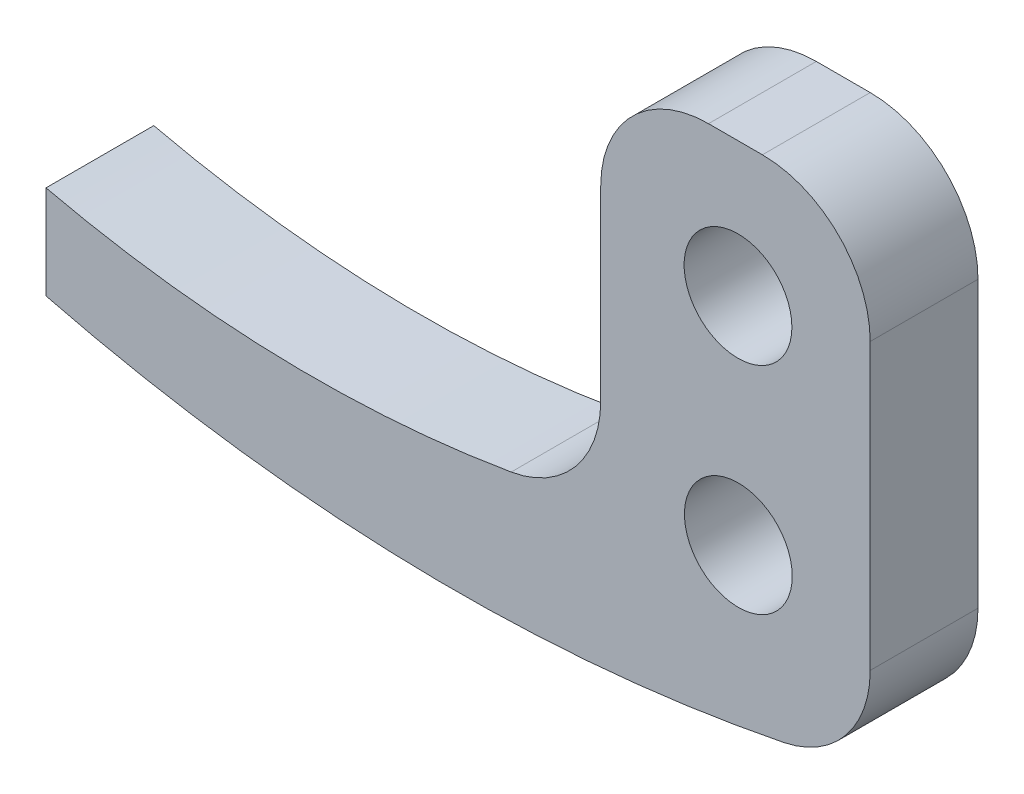
from build123d import *

# Parameters (mm, degrees)
SKETCH2_R           = 1
BOSS_EXTRUDE2_DEPTH = 2
FILLET1_R           = 2


with BuildPart() as part:
    # Sketch2 → Boss-Extrude2 (new body)
    with BuildSketch(Plane.XY):
        with BuildLine():
            Line((-3.823163379, 5.957240807), (-3.823163379, 7.694831843))
            ThreePointArc((-3.823163379, 7.694831843), (1.329416424, 7.130014771), (6.469831661, 7.796519188))
            Line((6.469831661, 7.796519188), (6.469831661, 14.872622199))
            Line((6.469831661, 14.872622199), (11.469831661, 14.872622199))
            Line((11.469831661, 14.872622199), (11.469831661, 9.743127337))
            Line((11.469831661, 9.743127337), (11.469831661, 5.993601449))
            ThreePointArc((11.469831661, 5.993601449), (3.825609616, 5.018374254), (-3.823163379, 5.957240807))
        make_face()
        with Locations((9.023220077, 8.376253999)):
            Circle(SKETCH2_R, mode=Mode.SUBTRACT)
        with Locations((9.016702167, 12.376248688)):
            Circle(SKETCH2_R, mode=Mode.SUBTRACT)
    extrude(amount=BOSS_EXTRUDE2_DEPTH)

    # Fillet1
    fillet1_edges = [part.edges().sort_by_distance(p)[0] for p in [
        (6.469831661, 7.796519188, 1),
        (6.469831661, 14.872622199, 1),
        (11.469831661, 14.872622199, 1),
        (11.469831661, 5.993601449, 1),
    ]]
    fillet(fillet1_edges, radius=FILLET1_R)


solid = part.part
